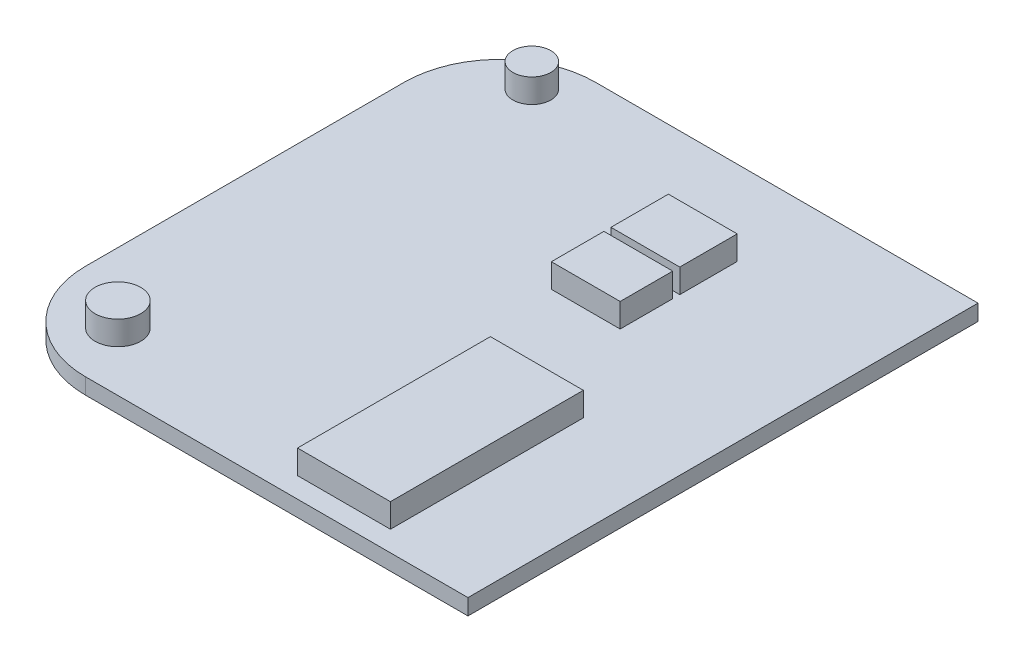
from build123d import *

# Parameters (mm, degrees)
BOSS_EXTRUDE1_DEPTH = 1
SKETCH2_W           = 4.317372505
SKETCH2_H           = 3.603476264
SKETCH2_H_2         = 3.297520732
SKETCH2_W_2         = 5.830152634
SKETCH2_H_3         = 12.102241037
BOSS_EXTRUDE2_DEPTH = 1.5
SKETCH3_R           = 1.433043964
SKETCH3_R_2         = 1.189827068
BOSS_EXTRUDE3_DEPTH = 1.5


with BuildPart() as part:
    # Sketch1 → Boss-Extrude1 (new body)
    with BuildSketch(Plane(origin=(0, 0, 0), x_dir=(1, 0, 0), z_dir=(0, 1, 0))):
        with BuildLine():
            Line((-6.992736077, 15.263922518), (17.007263923, 15.263922518))
            Line((17.007263923, 15.263922518), (17.007263923, -16.736077482))
            Line((17.007263923, -16.736077482), (-6.992736077, -16.736077482))
            ThreePointArc((-6.992736077, -16.736077482), (-11.235376765, -14.978718169), (-12.992736077, -10.736077482))
            Line((-12.992736077, -10.736077482), (-12.992736077, 9.263922518))
            ThreePointArc((-12.992736077, 9.263922518), (-11.235376765, 13.506563205), (-6.992736077, 15.263922518))
        make_face()
    extrude(amount=BOSS_EXTRUDE1_DEPTH)

    # Sketch2 → Boss-Extrude2 (add)
    with BuildSketch(Plane(origin=(0, 1, 0), x_dir=(1, 0, 0), z_dir=(0, 1, 0))):
        with Locations((5.032824182, 8.170628001)):
            Rectangle(SKETCH2_W, SKETCH2_H)
        with Locations((5.032824182, 4.278193734)):
            Rectangle(SKETCH2_W, SKETCH2_H_2)
        with Locations((7.947900499, -9.404817551)):
            Rectangle(SKETCH2_W_2, SKETCH2_H_3)
    extrude(amount=BOSS_EXTRUDE2_DEPTH)

    # Sketch3 → Boss-Extrude3 (add)
    with BuildSketch(Plane(origin=(0, 1, 0), x_dir=(1, 0, 0), z_dir=(0, 1, 0))):
        with Locations((-8.616192044, -13.076283933)):
            Circle(SKETCH3_R)
        with Locations((-8.616192044, 12.895941215)):
            Circle(SKETCH3_R_2)
    extrude(amount=BOSS_EXTRUDE3_DEPTH)


solid = part.part
